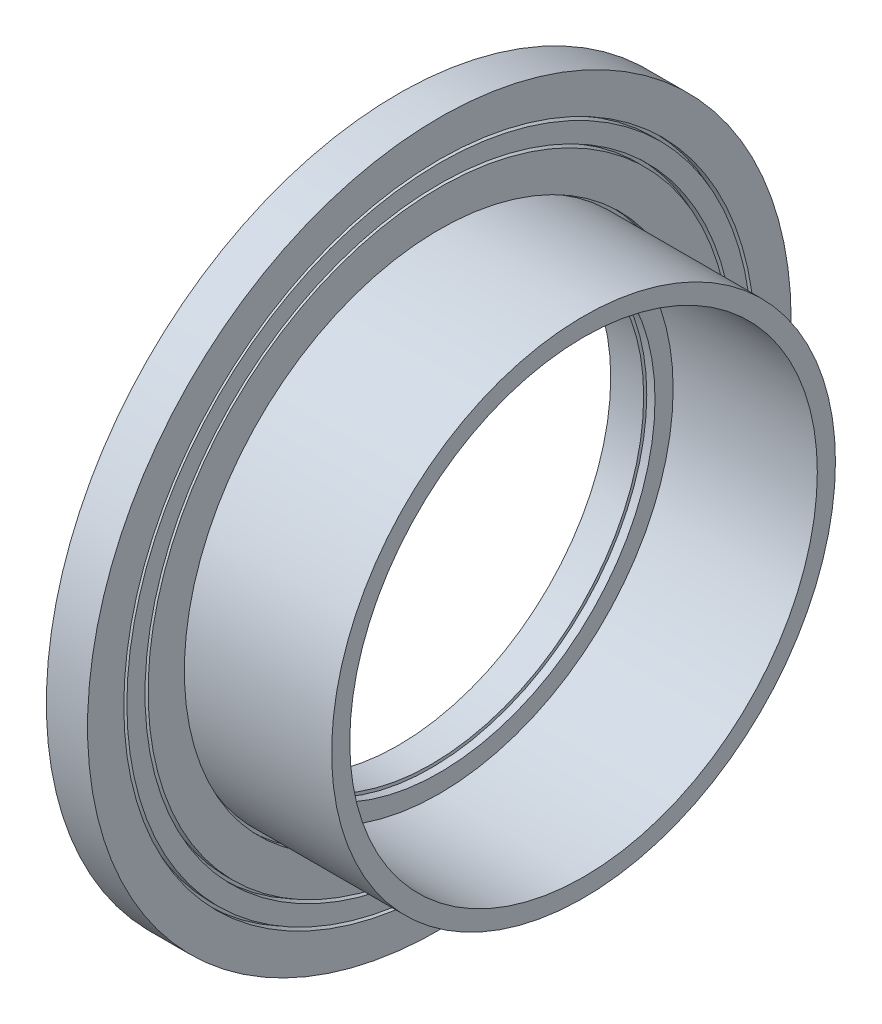
from build123d import *

# Parameters (mm, degrees)
SKETCH1_R           = 17.08
SKETCH1_R_2         = 10.32
BOSS_EXTRUDE1_DEPTH = 2
SKETCH2_R           = 12.23
SKETCH2_R_2         = 11.35
BOSS_EXTRUDE2_DEPTH = 7
SKETCH3_R           = 10.47
SKETCH3_R_2         = 10.32
CUT_EXTRUDE1_DEPTH  = 0.4
SKETCH12_R          = 12.38
SKETCH12_R_2        = 12.23
CUT_EXTRUDE7_DEPTH  = 0.4
SKETCH13_R          = 14.29
SKETCH13_R_2        = 14.14
CUT_EXTRUDE8_DEPTH  = 0.4
SKETCH14_R          = 15.32
SKETCH14_R_2        = 15.17
CUT_EXTRUDE9_DEPTH  = 0.4


with BuildPart() as part:
    # Sketch1 → Boss-Extrude1 (new body)
    with BuildSketch(Plane(origin=(0, 0, 0), x_dir=(0, 0, -1), z_dir=(1, 0, 0))):
        Circle(SKETCH1_R)
        Circle(SKETCH1_R_2, mode=Mode.SUBTRACT)
    extrude(amount=BOSS_EXTRUDE1_DEPTH)

    # Sketch2 → Boss-Extrude2 (add)
    with BuildSketch(Plane(origin=(2, 0, 0), x_dir=(0, 0, -1), z_dir=(1, 0, 0))):
        Circle(SKETCH2_R)
        Circle(SKETCH2_R_2, mode=Mode.SUBTRACT)
    extrude(amount=BOSS_EXTRUDE2_DEPTH)

    # Sketch3 → Cut-Extrude1 (cut)
    with BuildSketch(Plane(origin=(2, 0, 0), x_dir=(0, 0, -1), z_dir=(1, 0, 0))):
        Circle(SKETCH3_R)
        Circle(SKETCH3_R_2, mode=Mode.SUBTRACT)
    extrude(amount=-CUT_EXTRUDE1_DEPTH, mode=Mode.SUBTRACT)

    # Sketch12 → Cut-Extrude7 (cut)
    with BuildSketch(Plane(origin=(2, 0, 0), x_dir=(0, 0, -1), z_dir=(1, 0, 0))):
        Circle(SKETCH12_R)
        Circle(SKETCH12_R_2, mode=Mode.SUBTRACT)
    extrude(amount=-CUT_EXTRUDE7_DEPTH, mode=Mode.SUBTRACT)

    # Sketch13 → Cut-Extrude8 (cut)
    with BuildSketch(Plane(origin=(2, 0, 0), x_dir=(0, 0, -1), z_dir=(1, 0, 0))):
        Circle(SKETCH13_R)
        Circle(SKETCH13_R_2, mode=Mode.SUBTRACT)
    extrude(amount=-CUT_EXTRUDE8_DEPTH, mode=Mode.SUBTRACT)

    # Sketch14 → Cut-Extrude9 (cut)
    with BuildSketch(Plane(origin=(2, 0, 0), x_dir=(0, 0, -1), z_dir=(1, 0, 0))):
        Circle(SKETCH14_R)
        Circle(SKETCH14_R_2, mode=Mode.SUBTRACT)
    extrude(amount=-CUT_EXTRUDE9_DEPTH, mode=Mode.SUBTRACT)


solid = part.part
